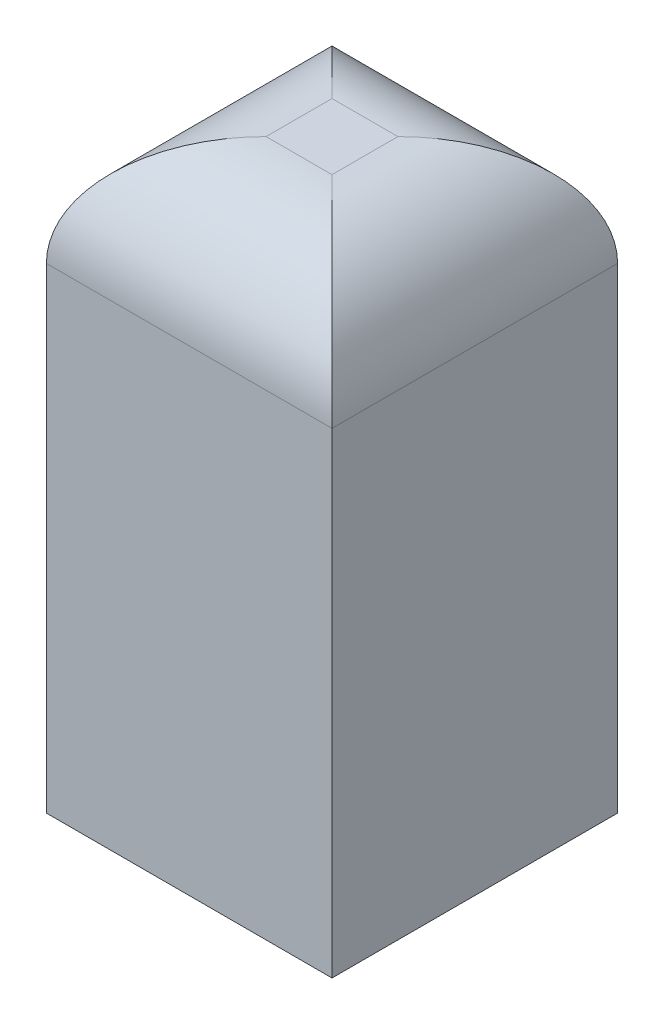
from build123d import *

# Parameters (mm, degrees)
SKETCH1_W           = 3.9
SKETCH1_H           = 3.9
BOSS_EXTRUDE1_DEPTH = 8
FILLET1_R           = 1.5


with BuildPart() as part:
    # Sketch1 → Boss-Extrude1 (new body)
    with BuildSketch(Plane(origin=(0, 0, 0), x_dir=(1, 0, 0), z_dir=(0, 1, 0))):
        Rectangle(SKETCH1_W, SKETCH1_H)
    extrude(amount=BOSS_EXTRUDE1_DEPTH)

    # Fillet1
    fillet1_edges = [part.edges().sort_by_distance(p)[0] for p in [
        (-1.95, 8, 0),
        (0, 8, 1.95),
        (1.95, 8, 0),
        (0, 8, -1.95),
    ]]
    fillet(fillet1_edges, radius=FILLET1_R)


solid = part.part
